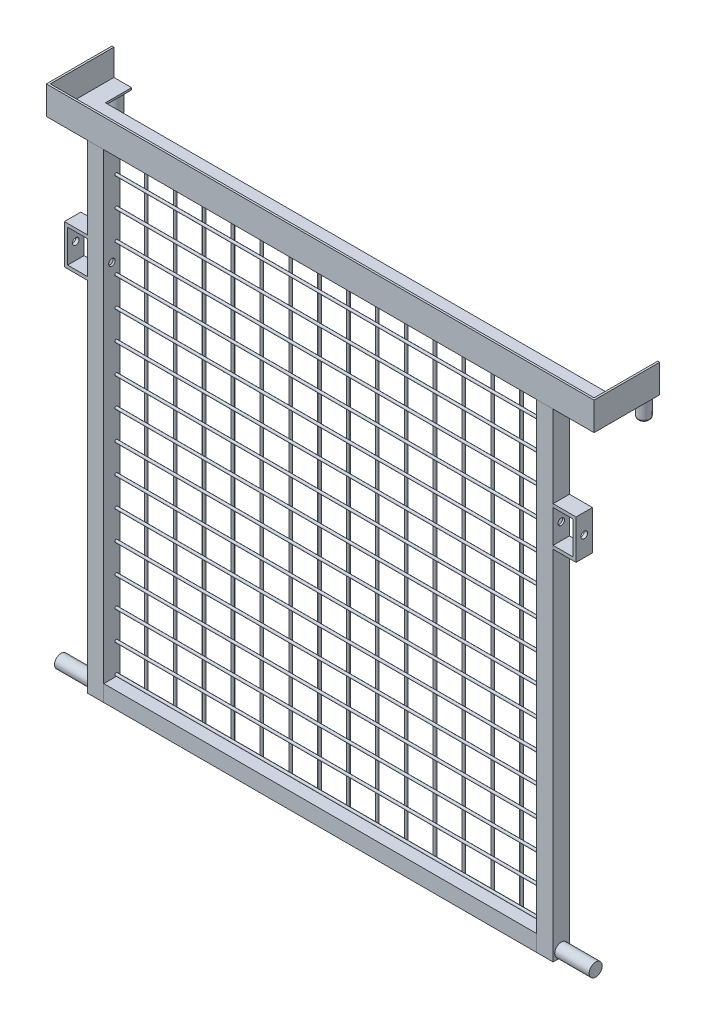
from build123d import *

# Parameters (mm, degrees)
ESTRUSIONE_ESTRUSIONE1_DEPTH   = 3
ESTRUSIONE_ESTRUSIONE2_DEPTH   = 40
SCHIZZO4_W                     = 25
SCHIZZO4_H                     = 25
SCHIZZO4_W_2                   = 19
SCHIZZO4_H_2                   = 19
ESTRUSIONE_ESTRUSIONE3_DEPTH   = 730
ESTRUSIONE_ESTRUSIONE3_2_DEPTH = 730
ESTRUSIONE_ESTRUSIONE4_REACH   = 1051.598
SCHIZZO5_W                     = 25
SCHIZZO5_H                     = 25
SCHIZZO5_W_2                   = 19
SCHIZZO5_H_2                   = 19
ESTRUSIONE_ESTRUSIONE5_REACH   = 848.88
SCHIZZO7_R                     = 2
ESTRUSIONE_ESTRUSIONE7_REACH   = 1051.598
SCHIZZO9_R                     = 2
SCHIZZO10_R                    = 10
ESTRUSIONE_ESTRUSIONE8_DEPTH   = 52.5
ESTRUSIONE_ESTRUSIONE9_DEPTH   = 25
TAGLIO_ESTRUSIONE1_START       = -680
SCHIZZO12_R                    = 5
TAGLIO_ESTRUSIONE1_DEPTH       = 680
SCHIZZO13_R                    = 9
ESTRUSIONE_ESTRUSIONE10_DEPTH  = 30
CUPOLA1_FACE_RADIUS            = 9
CUPOLA1_HEIGHT                 = 5


with BuildPart() as part:
    # Schizzo1 → Estrusione-Estrusione1 (new body)
    with BuildSketch(Plane(origin=(0, 0, 0), x_dir=(1, 0, 0), z_dir=(0, 1, 0))):
        Polygon((-417.5, 100), (-417.5, 0), (417.5, 0), (417.5, 100), (387.5, 100), (387.5, 60), (-387.5, 60), (-387.5, 100), align=None)
    extrude(amount=ESTRUSIONE_ESTRUSIONE1_DEPTH)

    # Schizzo2 → Estrusione-Estrusione2 (add)
    with BuildSketch(Plane(origin=(0, 3, 0), x_dir=(1, 0, 0), z_dir=(0, 1, 0))):
        Polygon((417.5, 0), (417.5, 100), (414.5, 100), (414.5, 3), (-414.5, 3), (-414.5, 100), (-417.5, 100), (-417.5, 0), align=None)
    extrude(amount=ESTRUSIONE_ESTRUSIONE2_DEPTH)


with BuildPart() as body_2:
    # Schizzo4 → Estrusione-Estrusione3 (new body)
    with BuildSketch(Plane.XZ):
        with Locations((-342.5, -12.5)):
            Rectangle(SCHIZZO4_W, SCHIZZO4_H)
        with Locations((-342.5, -12.5)):
            Rectangle(SCHIZZO4_W_2, SCHIZZO4_H_2, mode=Mode.SUBTRACT)
    extrude(amount=ESTRUSIONE_ESTRUSIONE3_DEPTH)


with BuildPart() as body_3:
    # Schizzo4 → Estrusione-Estrusione3 2 (new body)
    with BuildSketch(Plane.XZ):
        with Locations((342.5, -12.5)):
            Rectangle(SCHIZZO4_W, SCHIZZO4_H)
        with Locations((342.5, -12.5)):
            Rectangle(SCHIZZO4_W_2, SCHIZZO4_H_2, mode=Mode.SUBTRACT)
    extrude(amount=ESTRUSIONE_ESTRUSIONE3_2_DEPTH)


with BuildPart() as body_4:

    # Schizzo5 → Estrusione-Estrusione4 (new, up to next)
    with BuildSketch(Plane(origin=(-330, 0, 0), x_dir=(0, 0, -1), z_dir=(1, 0, 0)), mode=Mode.PRIVATE) as estrusione_estrusione4_sk1:
        with Locations((12.5, -717.5)):
            Rectangle(SCHIZZO5_W, SCHIZZO5_H)
        with Locations((12.5, -717.5)):
            Rectangle(SCHIZZO5_W_2, SCHIZZO5_H_2, mode=Mode.SUBTRACT)
    estrusione_estrusione4_tool1 = extrude(estrusione_estrusione4_sk1.sketch, amount=ESTRUSIONE_ESTRUSIONE4_REACH, mode=Mode.PRIVATE) - body_3.part
    add(estrusione_estrusione4_tool1.solids().sort_by_distance((-330, -729.646447, -12.5))[0])


with BuildPart() as body_5:

    # Schizzo7 → Estrusione-Estrusione5 (new, up to next)
    with BuildSketch(Plane.XZ, mode=Mode.PRIVATE) as estrusione_estrusione5_sk1:
        with Locations(Location((-288, -23, 0), (0, 0, 90))):
            Circle(SCHIZZO7_R)
    estrusione_estrusione5_tool1 = extrude(estrusione_estrusione5_sk1.sketch, amount=ESTRUSIONE_ESTRUSIONE5_REACH, mode=Mode.PRIVATE) - body_4.part
    # Schizzo7 → Estrusione-Estrusione5 (new, up to next)
    with BuildSketch(Plane.XZ, mode=Mode.PRIVATE) as estrusione_estrusione5_sk2:
        with Locations(Location((-244, -23, 0), (0, 0, 90))):
            Circle(SCHIZZO7_R)
    estrusione_estrusione5_tool2 = extrude(estrusione_estrusione5_sk2.sketch, amount=ESTRUSIONE_ESTRUSIONE5_REACH, mode=Mode.PRIVATE) - body_4.part
    # Schizzo7 → Estrusione-Estrusione5 (new, up to next)
    with BuildSketch(Plane.XZ, mode=Mode.PRIVATE) as estrusione_estrusione5_sk3:
        with Locations(Location((-200, -23, 0), (0, 0, 90))):
            Circle(SCHIZZO7_R)
    estrusione_estrusione5_tool3 = extrude(estrusione_estrusione5_sk3.sketch, amount=ESTRUSIONE_ESTRUSIONE5_REACH, mode=Mode.PRIVATE) - body_4.part
    # Schizzo7 → Estrusione-Estrusione5 (new, up to next)
    with BuildSketch(Plane.XZ, mode=Mode.PRIVATE) as estrusione_estrusione5_sk4:
        with Locations(Location((-156, -23, 0), (0, 0, 90))):
            Circle(SCHIZZO7_R)
    estrusione_estrusione5_tool4 = extrude(estrusione_estrusione5_sk4.sketch, amount=ESTRUSIONE_ESTRUSIONE5_REACH, mode=Mode.PRIVATE) - body_4.part
    # Schizzo7 → Estrusione-Estrusione5 (new, up to next)
    with BuildSketch(Plane.XZ, mode=Mode.PRIVATE) as estrusione_estrusione5_sk5:
        with Locations(Location((-112, -23, 0), (0, 0, 90))):
            Circle(SCHIZZO7_R)
    estrusione_estrusione5_tool5 = extrude(estrusione_estrusione5_sk5.sketch, amount=ESTRUSIONE_ESTRUSIONE5_REACH, mode=Mode.PRIVATE) - body_4.part
    # Schizzo7 → Estrusione-Estrusione5 (new, up to next)
    with BuildSketch(Plane.XZ, mode=Mode.PRIVATE) as estrusione_estrusione5_sk6:
        with Locations(Location((-68, -23, 0), (0, 0, 90))):
            Circle(SCHIZZO7_R)
    estrusione_estrusione5_tool6 = extrude(estrusione_estrusione5_sk6.sketch, amount=ESTRUSIONE_ESTRUSIONE5_REACH, mode=Mode.PRIVATE) - body_4.part
    # Schizzo7 → Estrusione-Estrusione5 (new, up to next)
    with BuildSketch(Plane.XZ, mode=Mode.PRIVATE) as estrusione_estrusione5_sk7:
        with Locations(Location((-24, -23, 0), (0, 0, 90))):
            Circle(SCHIZZO7_R)
    estrusione_estrusione5_tool7 = extrude(estrusione_estrusione5_sk7.sketch, amount=ESTRUSIONE_ESTRUSIONE5_REACH, mode=Mode.PRIVATE) - body_4.part
    # Schizzo7 → Estrusione-Estrusione5 (new, up to next)
    with BuildSketch(Plane.XZ, mode=Mode.PRIVATE) as estrusione_estrusione5_sk8:
        with Locations(Location((20, -23, 0), (0, 0, 90))):
            Circle(SCHIZZO7_R)
    estrusione_estrusione5_tool8 = extrude(estrusione_estrusione5_sk8.sketch, amount=ESTRUSIONE_ESTRUSIONE5_REACH, mode=Mode.PRIVATE) - body_4.part
    # Schizzo7 → Estrusione-Estrusione5 (new, up to next)
    with BuildSketch(Plane.XZ, mode=Mode.PRIVATE) as estrusione_estrusione5_sk9:
        with Locations(Location((64, -23, 0), (0, 0, 90))):
            Circle(SCHIZZO7_R)
    estrusione_estrusione5_tool9 = extrude(estrusione_estrusione5_sk9.sketch, amount=ESTRUSIONE_ESTRUSIONE5_REACH, mode=Mode.PRIVATE) - body_4.part
    # Schizzo7 → Estrusione-Estrusione5 (new, up to next)
    with BuildSketch(Plane.XZ, mode=Mode.PRIVATE) as estrusione_estrusione5_sk10:
        with Locations(Location((108, -23, 0), (0, 0, 90))):
            Circle(SCHIZZO7_R)
    estrusione_estrusione5_tool10 = extrude(estrusione_estrusione5_sk10.sketch, amount=ESTRUSIONE_ESTRUSIONE5_REACH, mode=Mode.PRIVATE) - body_4.part
    # Schizzo7 → Estrusione-Estrusione5 (new, up to next)
    with BuildSketch(Plane.XZ, mode=Mode.PRIVATE) as estrusione_estrusione5_sk11:
        with Locations(Location((152, -23, 0), (0, 0, 90))):
            Circle(SCHIZZO7_R)
    estrusione_estrusione5_tool11 = extrude(estrusione_estrusione5_sk11.sketch, amount=ESTRUSIONE_ESTRUSIONE5_REACH, mode=Mode.PRIVATE) - body_4.part
    # Schizzo7 → Estrusione-Estrusione5 (new, up to next)
    with BuildSketch(Plane.XZ, mode=Mode.PRIVATE) as estrusione_estrusione5_sk12:
        with Locations(Location((196, -23, 0), (0, 0, 90))):
            Circle(SCHIZZO7_R)
    estrusione_estrusione5_tool12 = extrude(estrusione_estrusione5_sk12.sketch, amount=ESTRUSIONE_ESTRUSIONE5_REACH, mode=Mode.PRIVATE) - body_4.part
    # Schizzo7 → Estrusione-Estrusione5 (new, up to next)
    with BuildSketch(Plane.XZ, mode=Mode.PRIVATE) as estrusione_estrusione5_sk13:
        with Locations(Location((240, -23, 0), (0, 0, 90))):
            Circle(SCHIZZO7_R)
    estrusione_estrusione5_tool13 = extrude(estrusione_estrusione5_sk13.sketch, amount=ESTRUSIONE_ESTRUSIONE5_REACH, mode=Mode.PRIVATE) - body_4.part
    # Schizzo7 → Estrusione-Estrusione5 (new, up to next)
    with BuildSketch(Plane.XZ, mode=Mode.PRIVATE) as estrusione_estrusione5_sk14:
        with Locations(Location((284, -23, 0), (0, 0, 90))):
            Circle(SCHIZZO7_R)
    estrusione_estrusione5_tool14 = extrude(estrusione_estrusione5_sk14.sketch, amount=ESTRUSIONE_ESTRUSIONE5_REACH, mode=Mode.PRIVATE) - body_4.part
    add(estrusione_estrusione5_tool1.solids().sort_by_distance((-288, 0, -23))[0])
    add(estrusione_estrusione5_tool2.solids().sort_by_distance((-244, 0, -23))[0])
    add(estrusione_estrusione5_tool3.solids().sort_by_distance((-200, 0, -23))[0])
    add(estrusione_estrusione5_tool4.solids().sort_by_distance((-156, 0, -23))[0])
    add(estrusione_estrusione5_tool5.solids().sort_by_distance((-112, 0, -23))[0])
    add(estrusione_estrusione5_tool6.solids().sort_by_distance((-68, 0, -23))[0])
    add(estrusione_estrusione5_tool7.solids().sort_by_distance((-24, 0, -23))[0])
    add(estrusione_estrusione5_tool8.solids().sort_by_distance((20, 0, -23))[0])
    add(estrusione_estrusione5_tool9.solids().sort_by_distance((64, 0, -23))[0])
    add(estrusione_estrusione5_tool10.solids().sort_by_distance((108, 0, -23))[0])
    add(estrusione_estrusione5_tool11.solids().sort_by_distance((152, 0, -23))[0])
    add(estrusione_estrusione5_tool12.solids().sort_by_distance((196, 0, -23))[0])
    add(estrusione_estrusione5_tool13.solids().sort_by_distance((240, 0, -23))[0])
    add(estrusione_estrusione5_tool14.solids().sort_by_distance((284, 0, -23))[0])


with BuildPart() as body_3_1:
    add(body_3.part)

    # Schizzo9 → Estrusione-Estrusione7 (add, up to next)
    with BuildSketch(Plane(origin=(-330, 0, 0), x_dir=(0, 0, -1), z_dir=(1, 0, 0)), mode=Mode.PRIVATE) as estrusione_estrusione7_sk1:
        with Locations(Location((19, -42, 0), (0, 0, 180))):
            Circle(SCHIZZO9_R)
    estrusione_estrusione7_tool1 = extrude(estrusione_estrusione7_sk1.sketch, amount=ESTRUSIONE_ESTRUSIONE7_REACH, mode=Mode.PRIVATE) - body_3_1.part
    # Schizzo9 → Estrusione-Estrusione7 (add, up to next)
    with BuildSketch(Plane(origin=(-330, 0, 0), x_dir=(0, 0, -1), z_dir=(1, 0, 0)), mode=Mode.PRIVATE) as estrusione_estrusione7_sk2:
        with Locations(Location((19, -86, 0), (0, 0, 180))):
            Circle(SCHIZZO9_R)
    estrusione_estrusione7_tool2 = extrude(estrusione_estrusione7_sk2.sketch, amount=ESTRUSIONE_ESTRUSIONE7_REACH, mode=Mode.PRIVATE) - body_3_1.part
    # Schizzo9 → Estrusione-Estrusione7 (add, up to next)
    with BuildSketch(Plane(origin=(-330, 0, 0), x_dir=(0, 0, -1), z_dir=(1, 0, 0)), mode=Mode.PRIVATE) as estrusione_estrusione7_sk3:
        with Locations(Location((19, -130, 0), (0, 0, 180))):
            Circle(SCHIZZO9_R)
    estrusione_estrusione7_tool3 = extrude(estrusione_estrusione7_sk3.sketch, amount=ESTRUSIONE_ESTRUSIONE7_REACH, mode=Mode.PRIVATE) - body_3_1.part
    # Schizzo9 → Estrusione-Estrusione7 (add, up to next)
    with BuildSketch(Plane(origin=(-330, 0, 0), x_dir=(0, 0, -1), z_dir=(1, 0, 0)), mode=Mode.PRIVATE) as estrusione_estrusione7_sk4:
        with Locations(Location((19, -174, 0), (0, 0, 180))):
            Circle(SCHIZZO9_R)
    estrusione_estrusione7_tool4 = extrude(estrusione_estrusione7_sk4.sketch, amount=ESTRUSIONE_ESTRUSIONE7_REACH, mode=Mode.PRIVATE) - body_3_1.part
    # Schizzo9 → Estrusione-Estrusione7 (add, up to next)
    with BuildSketch(Plane(origin=(-330, 0, 0), x_dir=(0, 0, -1), z_dir=(1, 0, 0)), mode=Mode.PRIVATE) as estrusione_estrusione7_sk5:
        with Locations(Location((19, -218, 0), (0, 0, 180))):
            Circle(SCHIZZO9_R)
    estrusione_estrusione7_tool5 = extrude(estrusione_estrusione7_sk5.sketch, amount=ESTRUSIONE_ESTRUSIONE7_REACH, mode=Mode.PRIVATE) - body_3_1.part
    # Schizzo9 → Estrusione-Estrusione7 (add, up to next)
    with BuildSketch(Plane(origin=(-330, 0, 0), x_dir=(0, 0, -1), z_dir=(1, 0, 0)), mode=Mode.PRIVATE) as estrusione_estrusione7_sk6:
        with Locations(Location((19, -262, 0), (0, 0, 180))):
            Circle(SCHIZZO9_R)
    estrusione_estrusione7_tool6 = extrude(estrusione_estrusione7_sk6.sketch, amount=ESTRUSIONE_ESTRUSIONE7_REACH, mode=Mode.PRIVATE) - body_3_1.part
    # Schizzo9 → Estrusione-Estrusione7 (add, up to next)
    with BuildSketch(Plane(origin=(-330, 0, 0), x_dir=(0, 0, -1), z_dir=(1, 0, 0)), mode=Mode.PRIVATE) as estrusione_estrusione7_sk7:
        with Locations(Location((19, -306, 0), (0, 0, 180))):
            Circle(SCHIZZO9_R)
    estrusione_estrusione7_tool7 = extrude(estrusione_estrusione7_sk7.sketch, amount=ESTRUSIONE_ESTRUSIONE7_REACH, mode=Mode.PRIVATE) - body_3_1.part
    # Schizzo9 → Estrusione-Estrusione7 (add, up to next)
    with BuildSketch(Plane(origin=(-330, 0, 0), x_dir=(0, 0, -1), z_dir=(1, 0, 0)), mode=Mode.PRIVATE) as estrusione_estrusione7_sk8:
        with Locations(Location((19, -350, 0), (0, 0, 180))):
            Circle(SCHIZZO9_R)
    estrusione_estrusione7_tool8 = extrude(estrusione_estrusione7_sk8.sketch, amount=ESTRUSIONE_ESTRUSIONE7_REACH, mode=Mode.PRIVATE) - body_3_1.part
    # Schizzo9 → Estrusione-Estrusione7 (add, up to next)
    with BuildSketch(Plane(origin=(-330, 0, 0), x_dir=(0, 0, -1), z_dir=(1, 0, 0)), mode=Mode.PRIVATE) as estrusione_estrusione7_sk9:
        with Locations(Location((19, -394, 0), (0, 0, 180))):
            Circle(SCHIZZO9_R)
    estrusione_estrusione7_tool9 = extrude(estrusione_estrusione7_sk9.sketch, amount=ESTRUSIONE_ESTRUSIONE7_REACH, mode=Mode.PRIVATE) - body_3_1.part
    # Schizzo9 → Estrusione-Estrusione7 (add, up to next)
    with BuildSketch(Plane(origin=(-330, 0, 0), x_dir=(0, 0, -1), z_dir=(1, 0, 0)), mode=Mode.PRIVATE) as estrusione_estrusione7_sk10:
        with Locations(Location((19, -438, 0), (0, 0, 180))):
            Circle(SCHIZZO9_R)
    estrusione_estrusione7_tool10 = extrude(estrusione_estrusione7_sk10.sketch, amount=ESTRUSIONE_ESTRUSIONE7_REACH, mode=Mode.PRIVATE) - body_3_1.part
    # Schizzo9 → Estrusione-Estrusione7 (add, up to next)
    with BuildSketch(Plane(origin=(-330, 0, 0), x_dir=(0, 0, -1), z_dir=(1, 0, 0)), mode=Mode.PRIVATE) as estrusione_estrusione7_sk11:
        with Locations(Location((19, -482, 0), (0, 0, 180))):
            Circle(SCHIZZO9_R)
    estrusione_estrusione7_tool11 = extrude(estrusione_estrusione7_sk11.sketch, amount=ESTRUSIONE_ESTRUSIONE7_REACH, mode=Mode.PRIVATE) - body_3_1.part
    # Schizzo9 → Estrusione-Estrusione7 (add, up to next)
    with BuildSketch(Plane(origin=(-330, 0, 0), x_dir=(0, 0, -1), z_dir=(1, 0, 0)), mode=Mode.PRIVATE) as estrusione_estrusione7_sk12:
        with Locations(Location((19, -526, 0), (0, 0, 180))):
            Circle(SCHIZZO9_R)
    estrusione_estrusione7_tool12 = extrude(estrusione_estrusione7_sk12.sketch, amount=ESTRUSIONE_ESTRUSIONE7_REACH, mode=Mode.PRIVATE) - body_3_1.part
    # Schizzo9 → Estrusione-Estrusione7 (add, up to next)
    with BuildSketch(Plane(origin=(-330, 0, 0), x_dir=(0, 0, -1), z_dir=(1, 0, 0)), mode=Mode.PRIVATE) as estrusione_estrusione7_sk13:
        with Locations(Location((19, -570, 0), (0, 0, 180))):
            Circle(SCHIZZO9_R)
    estrusione_estrusione7_tool13 = extrude(estrusione_estrusione7_sk13.sketch, amount=ESTRUSIONE_ESTRUSIONE7_REACH, mode=Mode.PRIVATE) - body_3_1.part
    # Schizzo9 → Estrusione-Estrusione7 (add, up to next)
    with BuildSketch(Plane(origin=(-330, 0, 0), x_dir=(0, 0, -1), z_dir=(1, 0, 0)), mode=Mode.PRIVATE) as estrusione_estrusione7_sk14:
        with Locations(Location((19, -614, 0), (0, 0, 180))):
            Circle(SCHIZZO9_R)
    estrusione_estrusione7_tool14 = extrude(estrusione_estrusione7_sk14.sketch, amount=ESTRUSIONE_ESTRUSIONE7_REACH, mode=Mode.PRIVATE) - body_3_1.part
    # Schizzo9 → Estrusione-Estrusione7 (add, up to next)
    with BuildSketch(Plane(origin=(-330, 0, 0), x_dir=(0, 0, -1), z_dir=(1, 0, 0)), mode=Mode.PRIVATE) as estrusione_estrusione7_sk15:
        with Locations(Location((19, -658, 0), (0, 0, 180))):
            Circle(SCHIZZO9_R)
    estrusione_estrusione7_tool15 = extrude(estrusione_estrusione7_sk15.sketch, amount=ESTRUSIONE_ESTRUSIONE7_REACH, mode=Mode.PRIVATE) - body_3_1.part
    # Schizzo9 → Estrusione-Estrusione7 (add, up to next)
    with BuildSketch(Plane(origin=(-330, 0, 0), x_dir=(0, 0, -1), z_dir=(1, 0, 0)), mode=Mode.PRIVATE) as estrusione_estrusione7_sk16:
        with Locations(Location((19, -702, 0), (0, 0, 180))):
            Circle(SCHIZZO9_R)
    estrusione_estrusione7_tool16 = extrude(estrusione_estrusione7_sk16.sketch, amount=ESTRUSIONE_ESTRUSIONE7_REACH, mode=Mode.PRIVATE) - body_3_1.part

    add(body_2.part)  # Estrusione-Estrusione7 merges body 2
    add(estrusione_estrusione7_tool1.solids().sort_by_distance((-330, -42, -19))[0])
    add(estrusione_estrusione7_tool2.solids().sort_by_distance((-330, -86, -19))[0])
    add(estrusione_estrusione7_tool3.solids().sort_by_distance((-330, -130, -19))[0])
    add(estrusione_estrusione7_tool4.solids().sort_by_distance((-330, -174, -19))[0])
    add(estrusione_estrusione7_tool5.solids().sort_by_distance((-330, -218, -19))[0])
    add(estrusione_estrusione7_tool6.solids().sort_by_distance((-330, -262, -19))[0])
    add(estrusione_estrusione7_tool7.solids().sort_by_distance((-330, -306, -19))[0])
    add(estrusione_estrusione7_tool8.solids().sort_by_distance((-330, -350, -19))[0])
    add(estrusione_estrusione7_tool9.solids().sort_by_distance((-330, -394, -19))[0])
    add(estrusione_estrusione7_tool10.solids().sort_by_distance((-330, -438, -19))[0])
    add(estrusione_estrusione7_tool11.solids().sort_by_distance((-330, -482, -19))[0])
    add(estrusione_estrusione7_tool12.solids().sort_by_distance((-330, -526, -19))[0])
    add(estrusione_estrusione7_tool13.solids().sort_by_distance((-330, -570, -19))[0])
    add(estrusione_estrusione7_tool14.solids().sort_by_distance((-330, -614, -19))[0])
    add(estrusione_estrusione7_tool15.solids().sort_by_distance((-330, -658, -19))[0])
    add(estrusione_estrusione7_tool16.solids().sort_by_distance((-330, -702, -19))[0])


with BuildPart() as body_5_2:
    # Schizzo10 → Estrusione-Estrusione8 (new body)
    with BuildSketch(Plane(origin=(355, 0, 0), x_dir=(0, 0, -1), z_dir=(1, 0, 0))):
        with Locations((12.5, -720)):
            Circle(SCHIZZO10_R)
    extrude(amount=ESTRUSIONE_ESTRUSIONE8_DEPTH)


with BuildPart() as body_6:
    # Specchia1: mirrored copy
    add(body_5_2.part.mirror(Plane(origin=(0, 0, 0), x_dir=(0, 0, 1), z_dir=(1, 0, 0))))


with BuildPart() as body_7:
    # Schizzo11 → Estrusione-Estrusione9 (new body)
    with BuildSketch(Plane.XY):
        Polygon((355, -125), (390, -125), (390, -185), (355, -185), (355, -180), (385, -180), (385, -130), (355, -130), align=None)
    estrusione_estrusione9 = extrude(amount=-ESTRUSIONE_ESTRUSIONE9_DEPTH)


with BuildPart() as taglio_estrusione1_tool:
    # Schizzo12 → Taglio-Estrusione1 (new body)
    with BuildSketch(Plane(origin=(390, 0, 0), x_dir=(0, 0, -1), z_dir=(1, 0, 0)).offset(TAGLIO_ESTRUSIONE1_START)):
        with Locations((12.5, -155)):
            Circle(SCHIZZO12_R)
    taglio_estrusione1 = extrude(amount=TAGLIO_ESTRUSIONE1_DEPTH)


with BuildPart() as body_3_2:
    add(body_3_1.part)

    # Taglio-Estrusione1: cut by taglio_estrusione1_tool
    add(taglio_estrusione1_tool.part, mode=Mode.SUBTRACT)

    # Specchia3: Estrusione-Estrusione9, Taglio-Estrusione1 across plane
    add(estrusione_estrusione9.mirror(Plane(origin=(0, 0, 0), x_dir=(0, 0, 1), z_dir=(1, 0, 0))))
    add(taglio_estrusione1.mirror(Plane(origin=(0, 0, 0), x_dir=(0, 0, 1), z_dir=(1, 0, 0))), mode=Mode.SUBTRACT)


with BuildPart() as body_7_1:
    add(body_7.part)

    # Taglio-Estrusione1: cut by taglio_estrusione1_tool
    add(taglio_estrusione1_tool.part, mode=Mode.SUBTRACT)


with BuildPart() as body_8:
    # Schizzo13 → Estrusione-Estrusione10 (new body)
    with BuildSketch(Plane.XZ):
        with Locations(Location((402.5, -91, 0), (0, 0, 270))):
            Circle(SCHIZZO13_R)
    extrude(amount=ESTRUSIONE_ESTRUSIONE10_DEPTH)

    # Cupola1: an elliptical dome of height H over a round flat face of radius A is half a spheroid: the quarter ellipse of half axes A and H revolved about the face's axis
    with BuildSketch(Plane((402.5, -30, -91), x_dir=(0, 0, 1), z_dir=(1, 0, 0)), mode=Mode.PRIVATE) as cupola1_quarter:
        Ellipse(CUPOLA1_FACE_RADIUS, CUPOLA1_HEIGHT)
        Rectangle(CUPOLA1_FACE_RADIUS, CUPOLA1_HEIGHT, align=(Align.MIN, Align.MIN), mode=Mode.INTERSECT)
    revolve(cupola1_quarter.sketch, axis=Axis((402.5, -30, -91), (0, -1, 0)))


with BuildPart() as body_9:
    # Specchia5: mirrored copy
    add(body_8.part.mirror(Plane(origin=(0, 0, 0), x_dir=(0, 0, 1), z_dir=(1, 0, 0))))


solid = Compound([part.part, body_4.part, body_5.part, body_5_2.part, body_6.part, body_3_2.part, body_7_1.part, body_8.part, body_9.part])
